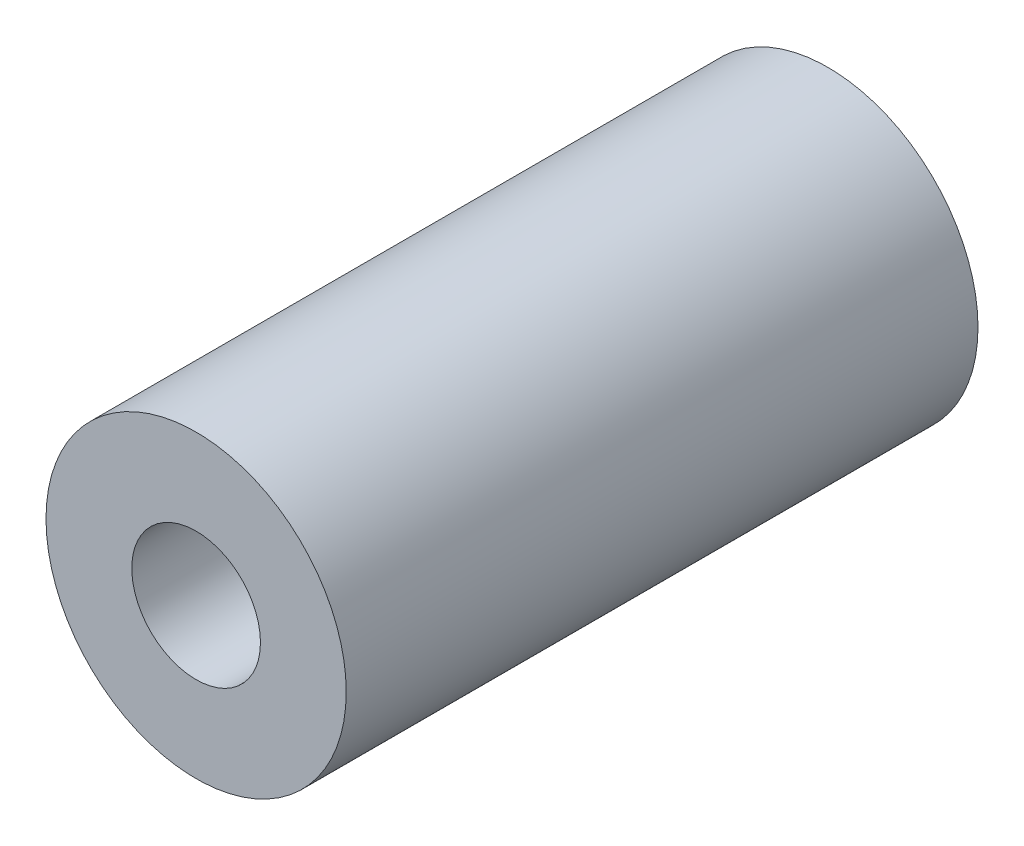
from build123d import *

# Parameters (mm, degrees)
SKETCH1_W = 14.73
SKETCH1_H = 2


with BuildPart() as part:
    # Sketch1 → Revolve1 (revolve)
    with BuildSketch(Plane(origin=(0, 0, 0), x_dir=(0, 0, -1), z_dir=(1, 0, 0))):
        with Locations((7.365, 2.5)):
            Rectangle(SKETCH1_W, SKETCH1_H)
    revolve(axis=Axis((0, 0, 0), (0, 0, -1)))


solid = part.part
